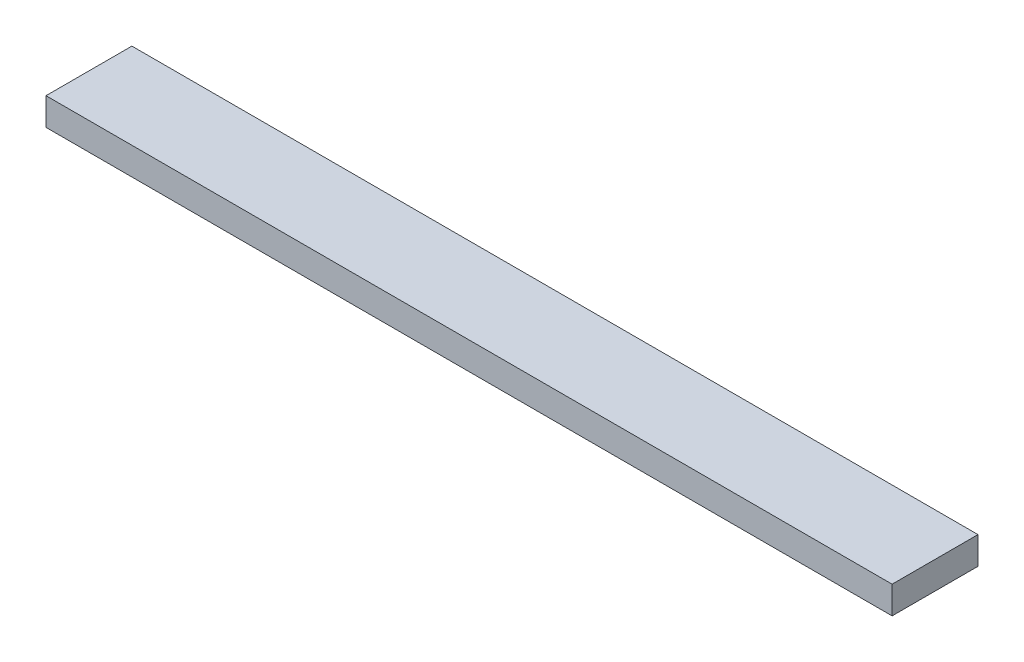
from build123d import *

# Parameters (mm, degrees)
SKETCH1_W           = 98.5
SKETCH1_H           = 10
BOSS_EXTRUDE1_DEPTH = 3.2


with BuildPart() as part:
    # Sketch1 → Boss-Extrude1 (new body)
    with BuildSketch(Plane(origin=(0, 0, 0), x_dir=(1, 0, 0), z_dir=(0, 1, 0))):
        with Locations((5.333684951, 6.567862166)):
            Rectangle(SKETCH1_W, SKETCH1_H)
    extrude(amount=BOSS_EXTRUDE1_DEPTH)


solid = part.part
